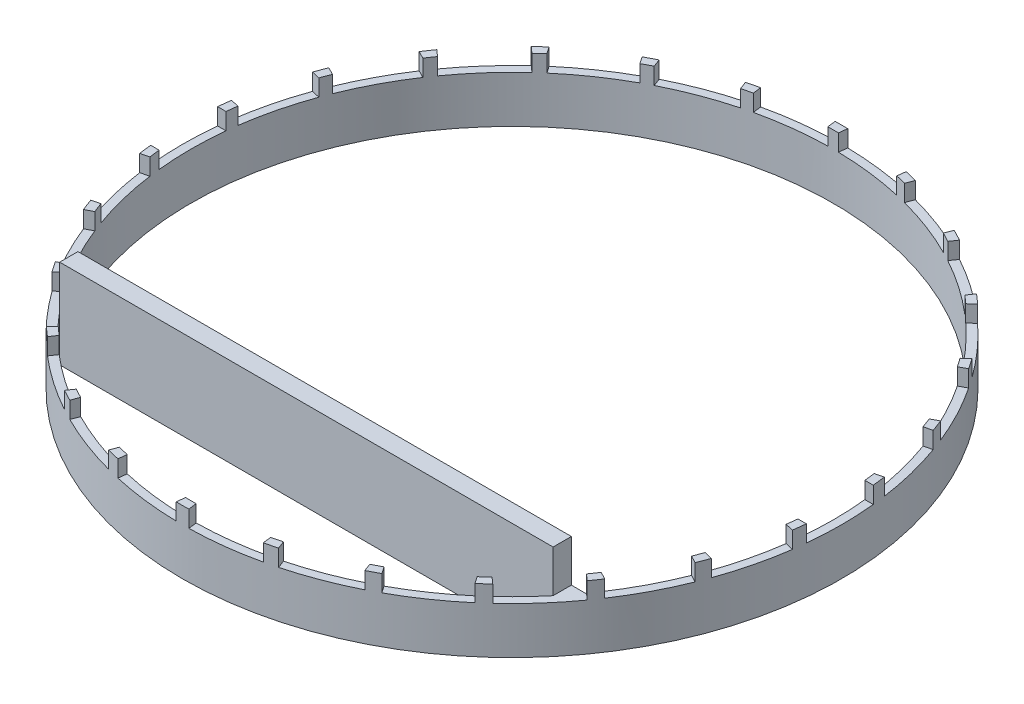
from build123d import *

# Parameters (mm, degrees)
BOSS_EXTRUDE1_DEPTH = 19
SKETCH2_W           = 20
SKETCH2_H           = 11
CUT_EXTRUDE1_DEPTH  = 141.589828935
CIRPATTERN1_COUNT   = 26
SKETCH3_W           = 147.494656174
SKETCH3_H           = 5.46
BOSS_EXTRUDE2_DEPTH = 12.6


with BuildPart() as part:
    # Sketch1 → Boss-Extrude1 (new body)
    with BuildSketch(Plane(origin=(0, 0, 0), x_dir=(1, 0, 0), z_dir=(0, 1, 0))):
        with BuildLine():
            ThreePointArc((76.973491541, -61.46), (79.050100656, -58.765054125), (81.032400927, -56))
            Line((81.032400927, -56), (77.974354758, -56))
            ThreePointArc((77.974354758, -56), (75.90994771, -58.76801714), (73.747328087, -61.46))
            Line((73.747328087, -61.46), (76.973491541, -61.46))
        make_face()
        with BuildLine():
            ThreePointArc((73.747328087, -61.46), (75.90994771, -58.76801714), (77.974354758, -56))
            Line((77.974354758, -56), (-77.974354758, -56))
            ThreePointArc((-77.974354758, -56), (-75.90994771, -58.76801714), (-73.747328087, -61.46))
            Line((-73.747328087, -61.46), (73.747328087, -61.46))
        make_face()
        with BuildLine():
            ThreePointArc((-73.747328087, -61.46), (-75.90994771, -58.76801714), (-77.974354758, -56))
            Line((-77.974354758, -56), (-81.032400927, -56))
            ThreePointArc((-81.032400927, -56), (-79.050100656, -58.765054125), (-76.973491541, -61.46))
            Line((-76.973491541, -61.46), (-73.747328087, -61.46))
        make_face()
        with BuildLine():
            Line((77.974354758, -56), (81.032400927, -56))
            ThreePointArc((81.032400927, -56), (94.031753922, -29.330517458), (98.5, 0))
            ThreePointArc((98.5, 0), (-29.330517458, 94.031753922), (-81.032400927, -56))
            Line((-81.032400927, -56), (-77.974354758, -56))
            ThreePointArc((-77.974354758, -56), (-29.414808713, 91.382542252), (96, 0))
            ThreePointArc((96, 0), (91.382542252, -29.414808713), (77.974354758, -56))
        make_face()
        with BuildLine():
            ThreePointArc((-76.973491541, -61.46), (0, -98.5), (76.973491541, -61.46))
            Line((76.973491541, -61.46), (73.747328087, -61.46))
            ThreePointArc((73.747328087, -61.46), (0, -96), (-73.747328087, -61.46))
            Line((-73.747328087, -61.46), (-76.973491541, -61.46))
        make_face()
    extrude(amount=BOSS_EXTRUDE1_DEPTH)

    # Sketch2 → Cut-Extrude1 (cut, through all)
    with BuildSketch(Plane(origin=(0, 0, 0), x_dir=(0, 0, -1), z_dir=(1, 0, 0))):
        with Locations((0, 19.5)):
            Rectangle(SKETCH2_W, SKETCH2_H)
    cut_extrude1 = extrude(amount=-CUT_EXTRUDE1_DEPTH, mode=Mode.SUBTRACT)

    # CirPattern1: Cut-Extrude1 ×26 about axis
    cirpattern1_axis = Axis((0, 0, 0), (0, 1, 0))
    for i in range(1, CIRPATTERN1_COUNT):
        add(cut_extrude1.rotate(cirpattern1_axis, i * 360 / CIRPATTERN1_COUNT), mode=Mode.SUBTRACT)

    # Sketch3 → Boss-Extrude2 (add)
    with BuildSketch(Plane(origin=(0, 14, 0), x_dir=(1, 0, 0), z_dir=(0, 1, 0))):
        with Locations((0, -58.73)):
            Rectangle(SKETCH3_W, SKETCH3_H)
    extrude(amount=BOSS_EXTRUDE2_DEPTH)


solid = part.part
